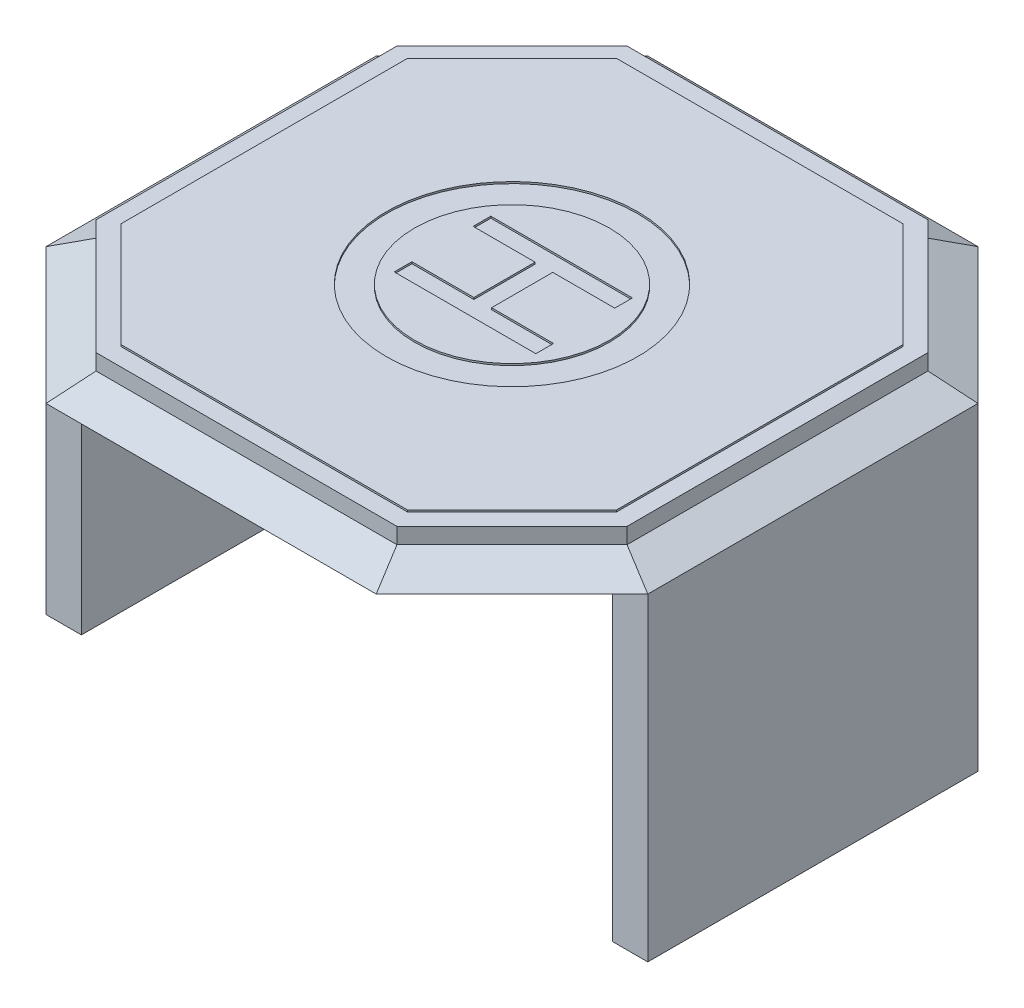
from build123d import *

# Parameters (mm, degrees)
EXTRUDE_2_DEPTH     = 100
SKETCH_8_R          = 355
SKETCH_8_R_2        = 275
CUT_EXTRUDE_1_DEPTH = 5
CUT_EXTRUDE_2_DEPTH = 5
CUT_EXTRUDE_3_DEPTH = 5
SKETCH_13_W         = 100
SKETCH_13_H         = 932.842712474
EXTRUDE_3_DEPTH     = 900


with BuildPart() as part:
    # 草图2 → 凸台-拉伸2 (new body)
    with BuildSketch(Plane(origin=(0, 0, 0), x_dir=(1, 0, 0), z_dir=(0, 1, 0))):
        Polygon((-425, 750), (425, 750), (750, 425), (750, -425), (425, -750), (-425, -750), (-750, -425), (-750, 425), align=None)
    extrude(amount=EXTRUDE_2_DEPTH)

    # 草图4 → 放样4 section 0
    with BuildSketch(Plane.XZ):
        Polygon((-466.421356237, 850), (466.421356237, 850), (850, 466.421356237), (850, -466.421356237), (466.421356237, -850), (-466.421356237, -850), (-850, -466.421356237), (-850, 466.421356237), align=None)
    # 草图7 → 放样4 section 1
    with BuildSketch(Plane(origin=(0, 50, 0), x_dir=(1, 0, 0), z_dir=(0, 1, 0))):
        Polygon((750, -425), (425, -750), (-425, -750), (-750, -425), (-750, 425), (-425, 750), (425, 750), (750, 425), align=None)
    loft()

    # 草图8 → 切除-拉伸1 (cut)
    with BuildSketch(Plane(origin=(0, 100, 0), x_dir=(1, 0, 0), z_dir=(0, 1, 0))):
        Circle(SKETCH_8_R)
        Circle(SKETCH_8_R_2, mode=Mode.SUBTRACT)
    extrude(amount=-CUT_EXTRUDE_1_DEPTH, mode=Mode.SUBTRACT)

    # 草图9 → 切除-拉伸2 (cut)
    with BuildSketch(Plane(origin=(0, 100, 0), x_dir=(1, 0, 0), z_dir=(0, 1, 0))):
        Polygon((-196.260530097, 136.438578222), (203.739469903, 136.438578222), (203.739469903, 86.438578222), (28.739469903, 86.438578222), (28.739469903, -86.438578222), (203.739469903, -86.438578222), (203.739469903, -136.438578222), (-196.260530097, -136.438578222), (-196.260530097, -86.438578222), (-21.260530097, -86.438578222), (-21.260530097, 86.438578222), (-196.260530097, 86.438578222), align=None)
    extrude(amount=-CUT_EXTRUDE_2_DEPTH, mode=Mode.SUBTRACT)

    # 草图10 → 切除-拉伸3 (cut)
    with BuildSketch(Plane(origin=(0, 100, 0), x_dir=(1, 0, 0), z_dir=(0, 1, 0))):
        Polygon((425, 750), (-425, 750), (-750, 425), (-750, -425), (-425, -750), (425, -750), (750, -425), (750, 425), align=None)
        Polygon((700, 404.289321881), (700, -404.289321881), (404.289321881, -700), (-404.289321881, -700), (-700, -404.289321881), (-700, 404.289321881), (-404.289321881, 700), (404.289321881, 700), align=None, mode=Mode.SUBTRACT)
    extrude(amount=-CUT_EXTRUDE_3_DEPTH, mode=Mode.SUBTRACT)

    # 草图13 → 凸台-拉伸3 (add)
    with BuildSketch(Plane.XZ):
        with Locations((-800, 0)):
            Rectangle(SKETCH_13_W, SKETCH_13_H)
        with Locations((800, 0)):
            Rectangle(SKETCH_13_W, SKETCH_13_H)
    extrude(amount=EXTRUDE_3_DEPTH)


solid = part.part
